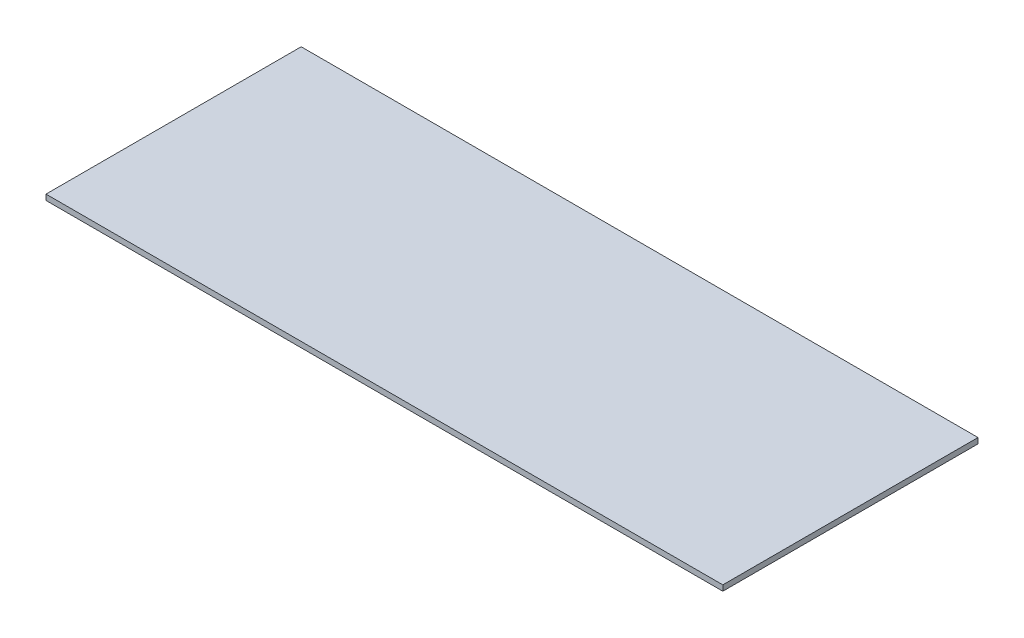
from build123d import *

# Parameters (mm, degrees)
SKETCH1_W           = 2440
SKETCH1_H           = 920
BOSS_EXTRUDE1_DEPTH = 20


with BuildPart() as part:
    # Sketch1 → Boss-Extrude1 (new body)
    with BuildSketch(Plane(origin=(0, 0, 0), x_dir=(1, 0, 0), z_dir=(0, 1, 0))):
        Rectangle(SKETCH1_W, SKETCH1_H)
    extrude(amount=BOSS_EXTRUDE1_DEPTH)


solid = part.part
